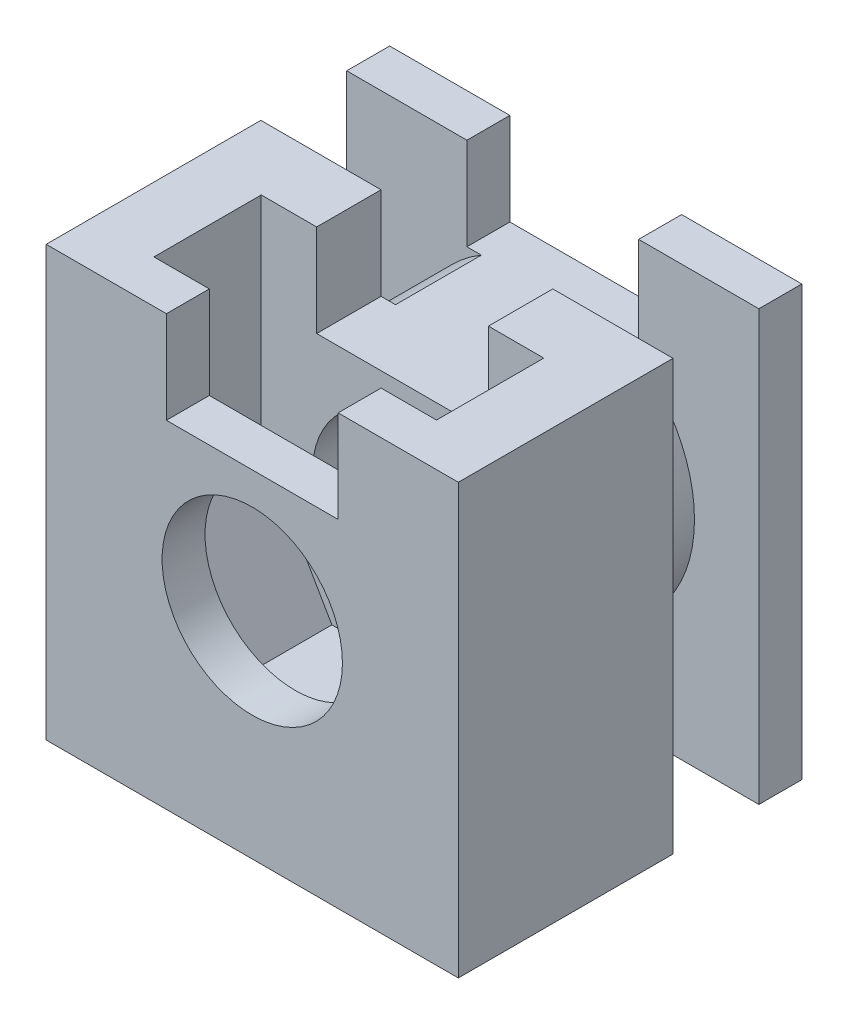
from build123d import *

# Parameters (mm, degrees)
BOSS_EXTRUDE1_DEPTH = 10
CUT_EXTRUDE1_START  = 4.5
CUT_EXTRUDE1_DEPTH  = 2.5
SKETCH3_R           = 2.1
CUT_EXTRUDE2_DEPTH  = 9
CUT_EXTRUDE7_START  = 1
SKETCH4_W           = 11.6
SKETCH4_H           = 12
SKETCH4_R           = 3.3
CUT_EXTRUDE7_DEPTH  = 2


with BuildPart() as part:
    # Sketch1 → Boss-Extrude1 (new body)
    with BuildSketch(Plane(origin=(0, 0, 0), x_dir=(1, 0, 0), z_dir=(0, 1, 0))):
        Polygon((4.8, 0), (0, 0), (-4.8, 0), (-4.8, -8), (4.8, -8), align=None)
    extrude(amount=BOSS_EXTRUDE1_DEPTH)

    # Sketch2 → Cut-Extrude1 (cut)
    with BuildSketch(Plane.XY.offset(CUT_EXTRUDE1_START)):
        Polygon((3.290896534, 10), (3.290896534, 5), (1.645448267, 7.85), (-1.645448267, 7.85), (-3.290896534, 5), (-3.290896534, 10), align=None)
        Polygon((-1.645448267, 2.15), (1.645448267, 2.15), (3.290896534, 5), (1.645448267, 7.85), (-1.645448267, 7.85), (-3.290896534, 5), align=None)
    extrude(amount=CUT_EXTRUDE1_DEPTH, mode=Mode.SUBTRACT)

    # Sketch3 → Cut-Extrude2 (cut, through all)
    with BuildSketch(Plane.XY):
        with Locations((0, 5)):
            Circle(SKETCH3_R)
        Polygon((0, 7.85), (2, 7.85), (2, 10), (-2, 10), (-2, 7.85), align=None)
    extrude(amount=CUT_EXTRUDE2_DEPTH, mode=Mode.SUBTRACT)

    # Sketch4 → Cut-Extrude7 (cut)
    with BuildSketch(Plane.XY.offset(CUT_EXTRUDE7_START)):
        with Locations((0, 5)):
            Rectangle(SKETCH4_W, SKETCH4_H)
        with Locations((0, 5)):
            Circle(SKETCH4_R, mode=Mode.SUBTRACT)
    extrude(amount=CUT_EXTRUDE7_DEPTH, mode=Mode.SUBTRACT)


solid = part.part
